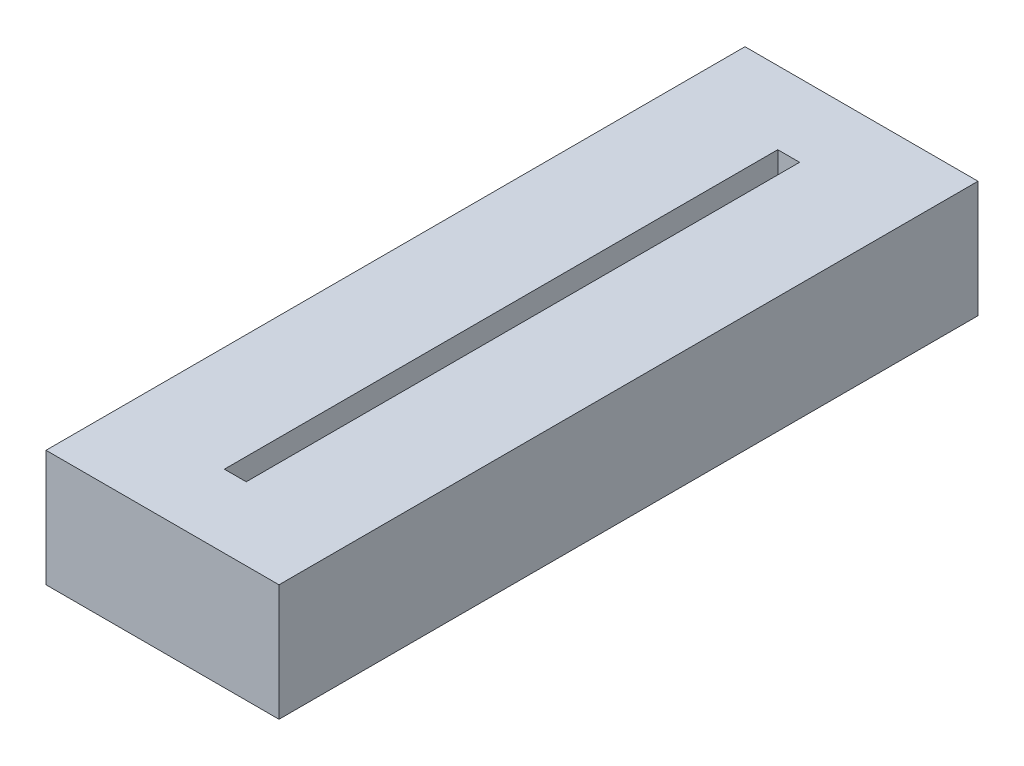
from build123d import *

# Parameters (mm, degrees)
SKETCH1_W           = 101.6
SKETCH1_H           = 50.8
BOSS_EXTRUDE1_DEPTH = 304.8
CUT_EXTRUDE1_DEPTH  = 19.05


with BuildPart() as part:
    # Sketch1 → Boss-Extrude1 (new body)
    with BuildSketch(Plane.XY):
        with Locations((50.8, 25.4)):
            Rectangle(SKETCH1_W, SKETCH1_H)
    extrude(amount=BOSS_EXTRUDE1_DEPTH)

    # Sketch2 → Cut-Extrude1 (cut)
    with BuildSketch(Plane(origin=(0, 50.8, 0), x_dir=(1, 0, 0), z_dir=(0, 1, 0))):
        Polygon((46.0375, -41.275), (46.0375, -31.75), (55.5625, -31.75), (55.5625, -41.275), (55.5625, -263.525), (55.5625, -273.05), (46.0375, -273.05), (46.0375, -263.525), align=None)
    extrude(amount=-CUT_EXTRUDE1_DEPTH, mode=Mode.SUBTRACT)


solid = part.part
